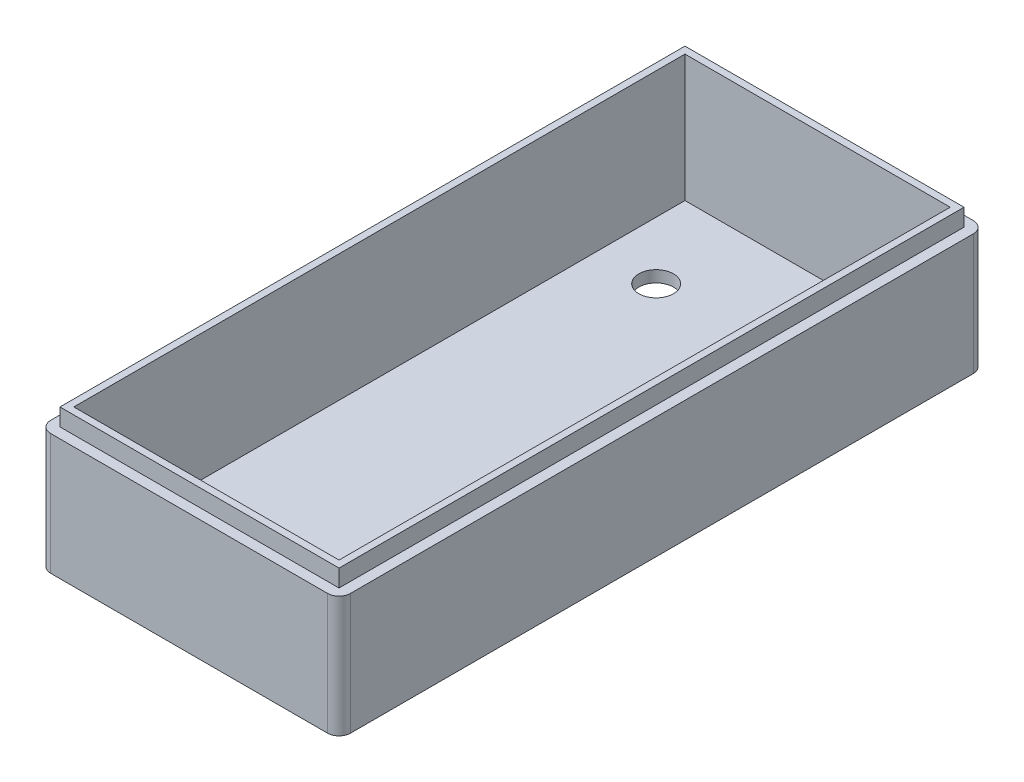
from build123d import *

# Parameters (mm, degrees)
SKETCH1_W               = 50
SKETCH1_H               = 110
BOSS_EXTRUDE1_DEPTH     = 2
SKETCH2_W               = 50
SKETCH2_H               = 110
SKETCH2_W_2             = 46
SKETCH2_H_2             = 106
BOSS_EXTRUDE3_DEPTH     = 11
SKETCH3_R               = 1.2
BOSS_EXTRUDE4_DEPTH     = 11
SKETCH4_W               = 52
SKETCH4_H               = 112
SKETCH4_W_2             = 50
SKETCH4_H_2             = 110
EXTRUDE_THIN1_DEPTH     = 13
FILLET2_R               = 2
EXTRUDE_THIN3_DEPTH     = 3
SKETCH6_R               = 1.8
BOSS_EXTRUDE5_DEPTH     = 2.8
SKETCH8_W               = 8
SKETCH8_H               = 3.6
CUT_EXTRUDE2_DEPTH      = 12.8
SKETCH11_W              = 13.1
SKETCH11_H              = 5.8
CUT_EXTRUDE5_DEPTH      = 3
SKETCH12_W              = 70
SKETCH12_H              = 9.973266712
CUT_EXTRUDE6_DEPTH      = 130
SKETCH13_W              = 46
SKETCH13_H              = 106
CUT_EXTRUDE7_DEPTH      = 130
SKETCH15_W              = 46
SKETCH15_H              = 106
BOSS_EXTRUDE6_DEPTH     = 60
SKETCH16_W              = 71.739839436
SKETCH16_H              = 55.166081701
CUT_EXTRUDE8_DEPTH      = 130
SKETCH17_W              = 110.8
SKETCH17_H              = 170.8
SKETCH17_W_2            = 48.4
SKETCH17_H_2            = 108.4
CUT_EXTRUDE_THIN1_DEPTH = 3
SKETCH18_W              = 3
SKETCH18_H              = 13.1
BOSS_EXTRUDE7_DEPTH     = 7
SKETCH19_W              = 3
SKETCH19_H              = 8
BOSS_EXTRUDE8_DEPTH     = 4.5
SKETCH20_R              = 6
SKETCH20_R_2            = 3
CUT_EXTRUDE9_DEPTH      = 4.5


with BuildPart() as part:
    # Sketch1 → Boss-Extrude1 (new body)
    with BuildSketch(Plane(origin=(0, 0, 0), x_dir=(1, 0, 0), z_dir=(0, 1, 0))):
        with Locations((-52.022587269, -1.919917864)):
            Rectangle(SKETCH1_W, SKETCH1_H)
    extrude(amount=BOSS_EXTRUDE1_DEPTH)

    # Sketch2 → Boss-Extrude3 (add)
    with BuildSketch(Plane(origin=(0, 2, 0), x_dir=(1, 0, 0), z_dir=(0, 1, 0))):
        with Locations((-52.022587269, -1.919917864)):
            Rectangle(SKETCH2_W, SKETCH2_H)
        with Locations((-52.022587269, -1.919917864)):
            Rectangle(SKETCH2_W_2, SKETCH2_H_2, mode=Mode.SUBTRACT)
    extrude(amount=BOSS_EXTRUDE3_DEPTH)

    # Sketch3 → Boss-Extrude4 (add)
    with BuildSketch(Plane(origin=(0, 2, 0), x_dir=(1, 0, 0), z_dir=(0, 1, 0))):
        with Locations((-31.022587269, 42.380082136)):
            Circle(SKETCH3_R)
        with Locations((-31.022587269, -52.919917864)):
            Circle(SKETCH3_R)
        with Locations((-56.322587269, 42.380082136)):
            Circle(SKETCH3_R)
        with Locations((-56.322587269, -52.919917864)):
            Circle(SKETCH3_R)
    extrude(amount=BOSS_EXTRUDE4_DEPTH)

    # Sketch4 → Extrude-Thin1 (add)
    with BuildSketch(Plane(origin=(0, 13, 0), x_dir=(1, 0, 0), z_dir=(0, 1, 0))):
        with Locations((-52.022587269, -1.919917864)):
            Rectangle(SKETCH4_W, SKETCH4_H)
        with Locations((-52.022587269, -1.919917864)):
            Rectangle(SKETCH4_W_2, SKETCH4_H_2, mode=Mode.SUBTRACT)
    extrude(amount=-EXTRUDE_THIN1_DEPTH)

    # Fillet2
    fillet2_edges = [part.edges().sort_by_distance(p)[0] for p in [
        (-26.022587269, 6.5, -54.080082136),
        (-26.022587269, 6.5, 57.919917864),
        (-78.022587269, 6.5, 57.919917864),
        (-78.022587269, 6.5, -54.080082136),
    ]]
    fillet(fillet2_edges, radius=FILLET2_R)

    # Sketch5 → Extrude-Thin3 (add)
    with BuildSketch(Plane(origin=(0, 13, 0), x_dir=(1, 0, 0), z_dir=(0, 1, 0))):
        with BuildLine():
            Line((-28.022587269, 54.080082136), (-76.022587269, 54.080082136))
            ThreePointArc((-76.022587269, 54.080082136), (-77.436800831, 53.494295698), (-78.022587269, 52.080082136))
            Line((-78.022587269, 52.080082136), (-78.022587269, -55.919917864))
            ThreePointArc((-78.022587269, -55.919917864), (-77.436800831, -57.334131427), (-76.022587269, -57.919917864))
            Line((-76.022587269, -57.919917864), (-28.022587269, -57.919917864))
            ThreePointArc((-28.022587269, -57.919917864), (-26.608373707, -57.334131427), (-26.022587269, -55.919917864))
            Line((-26.022587269, -55.919917864), (-26.022587269, 52.080082136))
            ThreePointArc((-26.022587269, 52.080082136), (-26.608373707, 53.494295698), (-28.022587269, 54.080082136))
        make_face()
        with BuildLine():
            Line((-28.022587269, 52.880082136), (-76.022587269, 52.880082136))
            ThreePointArc((-76.022587269, 52.880082136), (-76.588272694, 52.64576756), (-76.822587269, 52.080082136))
            Line((-76.822587269, 52.080082136), (-76.822587269, -55.919917864))
            ThreePointArc((-76.822587269, -55.919917864), (-76.588272694, -56.485603289), (-76.022587269, -56.719917864))
            Line((-76.022587269, -56.719917864), (-28.022587269, -56.719917864))
            ThreePointArc((-28.022587269, -56.719917864), (-27.456901844, -56.485603289), (-27.222587269, -55.919917864))
            Line((-27.222587269, -55.919917864), (-27.222587269, 52.080082136))
            ThreePointArc((-27.222587269, 52.080082136), (-27.456901844, 52.64576756), (-28.022587269, 52.880082136))
        make_face(mode=Mode.SUBTRACT)
    extrude(amount=EXTRUDE_THIN3_DEPTH)

    # Sketch6 → Boss-Extrude5 (add)
    with BuildSketch(Plane(origin=(0, 2, 0), x_dir=(1, 0, 0), z_dir=(0, 1, 0))):
        with Locations((-56.322587269, -52.919917864)):
            Circle(SKETCH6_R)
        with Locations((-31.022587269, -52.919917864)):
            Circle(SKETCH6_R)
        with Locations((-56.322587269, 42.380082136)):
            Circle(SKETCH6_R)
        with Locations((-31.022587269, 42.380082136)):
            Circle(SKETCH6_R)
    extrude(amount=BOSS_EXTRUDE5_DEPTH)

    # Sketch8 → Cut-Extrude2 (cut)
    with BuildSketch(Plane(origin=(-26.022587269, 0, 0), x_dir=(0, 0, -1), z_dir=(1, 0, 0))):
        with Locations((-44.619917864, 3.8)):
            Rectangle(SKETCH8_W, SKETCH8_H)
    extrude(amount=-CUT_EXTRUDE2_DEPTH, mode=Mode.SUBTRACT)

    # Sketch11 → Cut-Extrude5 (cut)
    with BuildSketch(Plane.ZY.offset(78.022587269)):
        with Locations((-43.530082136, 4.9)):
            Rectangle(SKETCH11_W, SKETCH11_H)
    extrude(amount=-CUT_EXTRUDE5_DEPTH, mode=Mode.SUBTRACT)

    # Sketch12 → Cut-Extrude6 (cut)
    with BuildSketch(Plane.XY.offset(57.919917864)):
        with Locations((-53.022587269, 15.377484965)):
            Rectangle(SKETCH12_W, SKETCH12_H)
    extrude(amount=-CUT_EXTRUDE6_DEPTH, mode=Mode.SUBTRACT)

    # Sketch13 → Cut-Extrude7 (cut)
    with BuildSketch(Plane(origin=(0, 2, 0), x_dir=(1, 0, 0), z_dir=(0, 1, 0))):
        with Locations((-52.022587269, -1.919917864)):
            Rectangle(SKETCH13_W, SKETCH13_H)
    extrude(amount=CUT_EXTRUDE7_DEPTH, mode=Mode.SUBTRACT)

    # Sketch15 → Boss-Extrude6 (add)
    with BuildSketch(Plane(origin=(0, 10.390851609, 0), x_dir=(1, 0, 0), z_dir=(0, 1, 0))):
        with BuildLine():
            Line((-76.022587269, -57.919917864), (-28.022587269, -57.919917864))
            ThreePointArc((-28.022587269, -57.919917864), (-26.608373707, -57.334131427), (-26.022587269, -55.919917864))
            Line((-26.022587269, -55.919917864), (-26.022587269, 52.080082136))
            ThreePointArc((-26.022587269, 52.080082136), (-26.608373707, 53.494295698), (-28.022587269, 54.080082136))
            Line((-28.022587269, 54.080082136), (-76.022587269, 54.080082136))
            ThreePointArc((-76.022587269, 54.080082136), (-77.436800831, 53.494295698), (-78.022587269, 52.080082136))
            Line((-78.022587269, 52.080082136), (-78.022587269, -55.919917864))
            ThreePointArc((-78.022587269, -55.919917864), (-77.436800831, -57.334131427), (-76.022587269, -57.919917864))
        make_face()
        with Locations((-52.022587269, -1.919917864)):
            Rectangle(SKETCH15_W, SKETCH15_H, mode=Mode.SUBTRACT)
    extrude(amount=BOSS_EXTRUDE6_DEPTH)

    # Sketch16 → Cut-Extrude8 (cut)
    with BuildSketch(Plane.XY.offset(57.919917864)):
        with Locations((-48.522353235, 51.583040851)):
            Rectangle(SKETCH16_W, SKETCH16_H)
    extrude(amount=-CUT_EXTRUDE8_DEPTH, mode=Mode.SUBTRACT)

    # Sketch17 → Cut-Extrude-Thin1 (cut)
    with BuildSketch(Plane(origin=(0, 24, 0), x_dir=(1, 0, 0), z_dir=(0, 1, 0))):
        with Locations((-52.022587269, -1.919917864)):
            Rectangle(SKETCH17_W, SKETCH17_H)
        with Locations((-52.022587269, -1.919917864)):
            Rectangle(SKETCH17_W_2, SKETCH17_H_2, mode=Mode.SUBTRACT)
    extrude(amount=-CUT_EXTRUDE_THIN1_DEPTH, mode=Mode.SUBTRACT)

    # Sketch18 → Boss-Extrude7 (add)
    with BuildSketch(Plane.XZ.offset(-7.8)):
        with Locations((-76.522587269, -43.530082136)):
            Rectangle(SKETCH18_W, SKETCH18_H)
    extrude(amount=BOSS_EXTRUDE7_DEPTH)

    # Sketch19 → Boss-Extrude8 (add)
    with BuildSketch(Plane.XZ.offset(-5.6)):
        with Locations((-27.522587269, 44.619917864)):
            Rectangle(SKETCH19_W, SKETCH19_H)
    extrude(amount=BOSS_EXTRUDE8_DEPTH)

    # Sketch20 → Cut-Extrude9 (cut)
    with BuildSketch(Plane(origin=(0, 2, 0), x_dir=(1, 0, 0), z_dir=(0, 1, 0))):
        with Locations((-65.022587269, -39.919917864)):
            Circle(SKETCH20_R)
        with Locations((-65.022587269, 36.080082136)):
            Circle(SKETCH20_R_2)
    extrude(amount=-CUT_EXTRUDE9_DEPTH, mode=Mode.SUBTRACT)


solid = part.part
